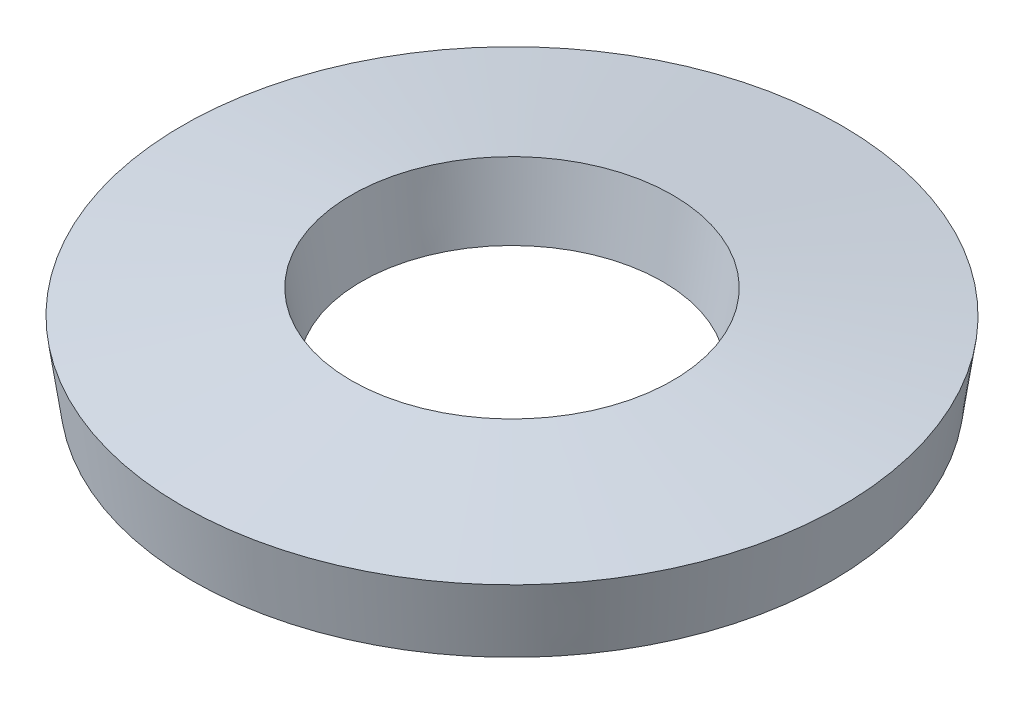
from build123d import *


with BuildPart() as part:
    # Sketch1 → Revolve1 (revolve)
    with BuildSketch(Plane.XY):
        Polygon((6.786710012, 0), (3.2, 0.515241642), (3.413289988, 2), (7, 1.484758358), align=None)
    revolve(axis=Axis((0, 0, 0), (0, 1, 0)))


solid = part.part
